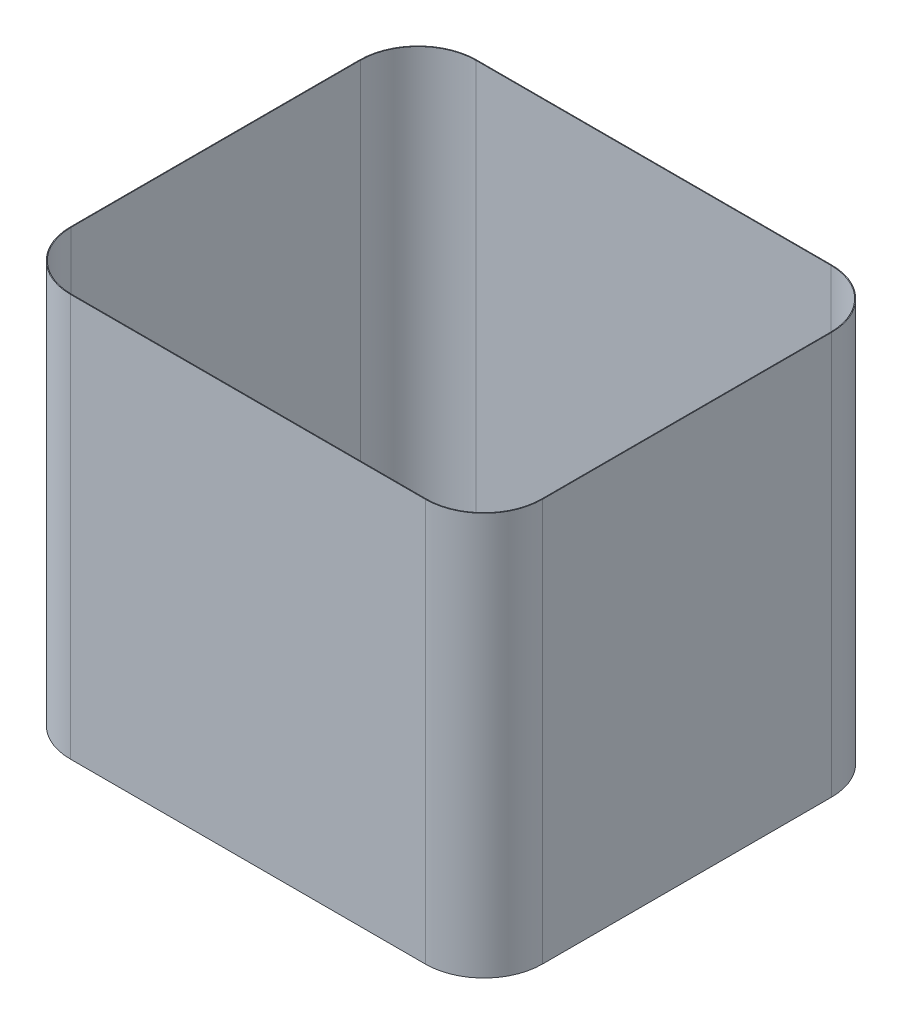
from build123d import *

# Parameters (mm, degrees)
BOSS_EXTRUDE1_DEPTH = 1397
SHELL1_T            = -2.54
CUT_EXTRUDE3_REACH  = 4.54


with BuildPart() as part:
    # Sketch1 → Boss-Extrude1 (new body)
    with BuildSketch(Plane(origin=(0, 0, 0), x_dir=(1, 0, 0), z_dir=(0, 1, 0))):
        with BuildLine():
            Line((-203.2, -406.4), (1028.7, -406.4))
            ThreePointArc((1028.7, -406.4), (1172.384097937, -346.884097937), (1231.9, -203.2))
            Line((1231.9, -203.2), (1231.9, 800.1))
            ThreePointArc((1231.9, 800.1), (1172.384097937, 943.784097937), (1028.7, 1003.3))
            Line((1028.7, 1003.3), (-203.2, 1003.3))
            ThreePointArc((-203.2, 1003.3), (-346.884097937, 943.784097937), (-406.4, 800.1))
            Line((-406.4, 800.1), (-406.4, -203.2))
            ThreePointArc((-406.4, -203.2), (-346.884097937, -346.884097937), (-203.2, -406.4))
        make_face()
    extrude(amount=BOSS_EXTRUDE1_DEPTH)

    # Shell1
    shell1_openings = [part.faces().sort_by_distance(p)[0] for p in [
        (412.75, 0, -298.45),
    ]]
    offset(amount=SHELL1_T, openings=shell1_openings, kind=Kind.INTERSECTION)

    # Sketch3 → Cut-Extrude3 (cut, up to next)
    with BuildSketch(Plane.XZ.offset(-1394.46), mode=Mode.PRIVATE) as cut_extrude3_sk1:
        with BuildLine():
            Line((-403.86, 203.2), (-403.86, -800.1))
            ThreePointArc((-403.86, -800.1), (-345.088046713, -941.988046713), (-203.2, -1000.76))
            Line((-203.2, -1000.76), (1028.7, -1000.76))
            ThreePointArc((1028.7, -1000.76), (1170.588046713, -941.988046713), (1229.36, -800.1))
            Line((1229.36, -800.1), (1229.36, 203.2))
            ThreePointArc((1229.36, 203.2), (1170.588046713, 345.088046713), (1028.7, 403.86))
            Line((1028.7, 403.86), (-203.2, 403.86))
            ThreePointArc((-203.2, 403.86), (-345.088046713, 345.088046713), (-403.86, 203.2))
        make_face()
    cut_extrude3_tool1 = extrude(cut_extrude3_sk1.sketch, amount=-CUT_EXTRUDE3_REACH, mode=Mode.PRIVATE) & part.part
    add(cut_extrude3_tool1.solids().sort_by_distance((412.75, 1394.46, -298.45))[0], mode=Mode.SUBTRACT)


solid = part.part
